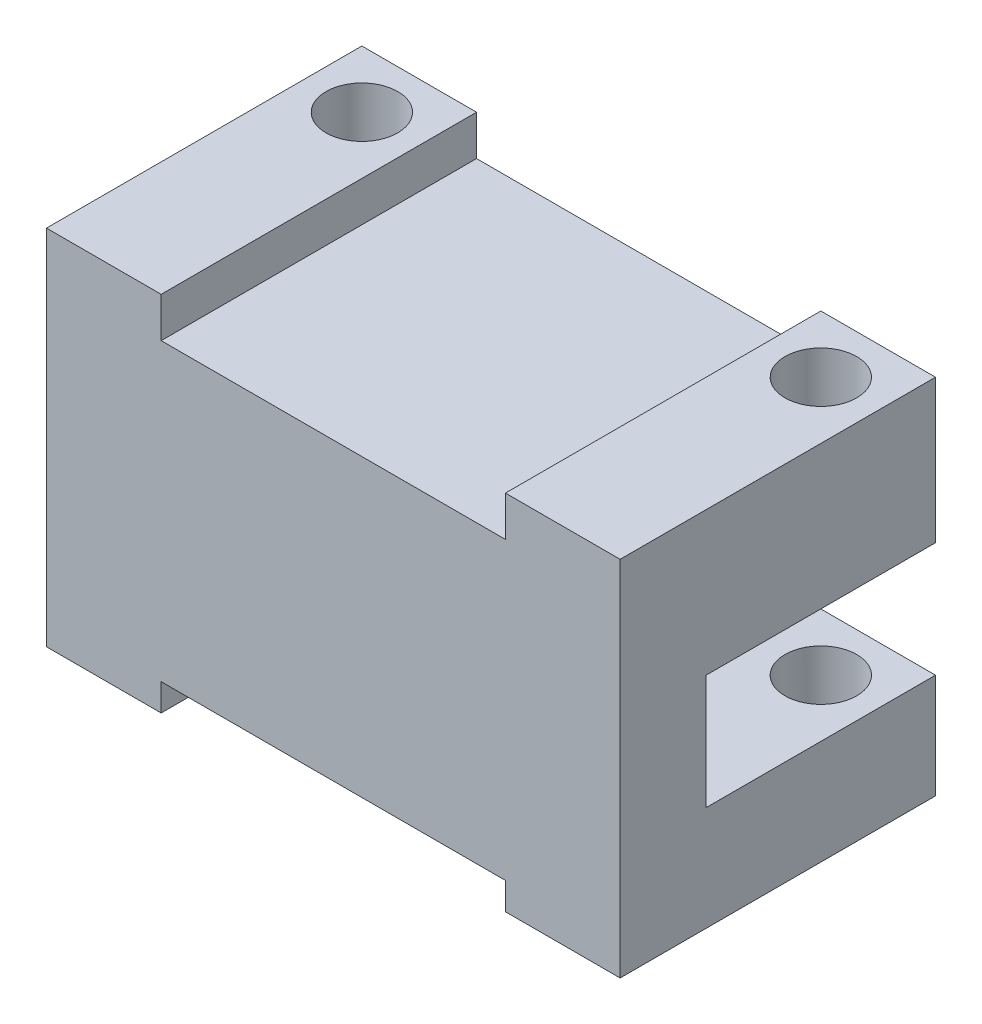
from build123d import *

# Parameters (mm, degrees)
BOSS_EXTRUDE1_DEPTH         = 3
SKETCH2_W                   = 20.0076
SKETCH2_H                   = 4.999999987
BOSS_EXTRUDE2_DEPTH         = 8
BOSS_EXTRUDE3_DEPTH         = 8
SKETCH4_W                   = 12.0076
SKETCH4_H                   = 1.4
CUT_EXTRUDE1_DEPTH          = 27.7
TAP_DRILL_FOR_M3_TAP1_D     = 2.5
TAP_DRILL_FOR_M3_TAP1_DEPTH = 15.5
TAP_DRILL_FOR_M3_TAP1_TIP   = 0.751075774


with BuildPart() as part:
    # Sketch1 → Boss-Extrude1 (new body)
    with BuildSketch(Plane.XY):
        Polygon((24.618539046, -84.902707764), (24.618539046, -85.849818272), (20.618539046, -85.849818272), (20.618539046, -73.202707764), (40.626139046, -73.202707764), (40.626139046, -85.849818272), (36.626139046, -85.849818272), (36.626139046, -84.902707764), align=None)
    extrude(amount=BOSS_EXTRUDE1_DEPTH)

    # Sketch2 → Boss-Extrude2 (add)
    with BuildSketch(Plane(origin=(0, 0, 0), x_dir=(-1, 0, 0), z_dir=(0, 0, -1))):
        with Locations((-30.622339046, -75.702707758)):
            Rectangle(SKETCH2_W, SKETCH2_H)
    extrude(amount=BOSS_EXTRUDE2_DEPTH)

    # Sketch3 → Boss-Extrude3 (add)
    with BuildSketch(Plane(origin=(0, 0, 0), x_dir=(-1, 0, 0), z_dir=(0, 0, -1))):
        Polygon((-40.626139046, -82.202707751), (-40.626139046, -85.849818272), (-36.626139046, -85.849818272), (-36.626139046, -84.902707764), (-24.618539046, -84.902707764), (-24.618539046, -85.849818272), (-20.618539046, -85.849818272), (-20.618539046, -82.202707751), align=None)
    extrude(amount=BOSS_EXTRUDE3_DEPTH)

    # Sketch4 → Cut-Extrude1 (cut)
    with BuildSketch(Plane.XY.offset(3)):
        with Locations((30.622339046, -73.902707764)):
            Rectangle(SKETCH4_W, SKETCH4_H)
    extrude(amount=-CUT_EXTRUDE1_DEPTH, mode=Mode.SUBTRACT)

    # Tap Drill for M3 Tap1
    with Locations(Plane(origin=(0, -73.202707764, 0), x_dir=(1, 0, 0), z_dir=(0, 1, 0))):
        with Locations((22.618539046, 6), (38.626139046, 6)):
            Hole(TAP_DRILL_FOR_M3_TAP1_D / 2, depth=TAP_DRILL_FOR_M3_TAP1_DEPTH)
            with Locations((0, 0, -(TAP_DRILL_FOR_M3_TAP1_DEPTH + TAP_DRILL_FOR_M3_TAP1_TIP / 2))):  # 118° drill point
                Cone(0, TAP_DRILL_FOR_M3_TAP1_D / 2, TAP_DRILL_FOR_M3_TAP1_TIP, mode=Mode.SUBTRACT)


solid = part.part
